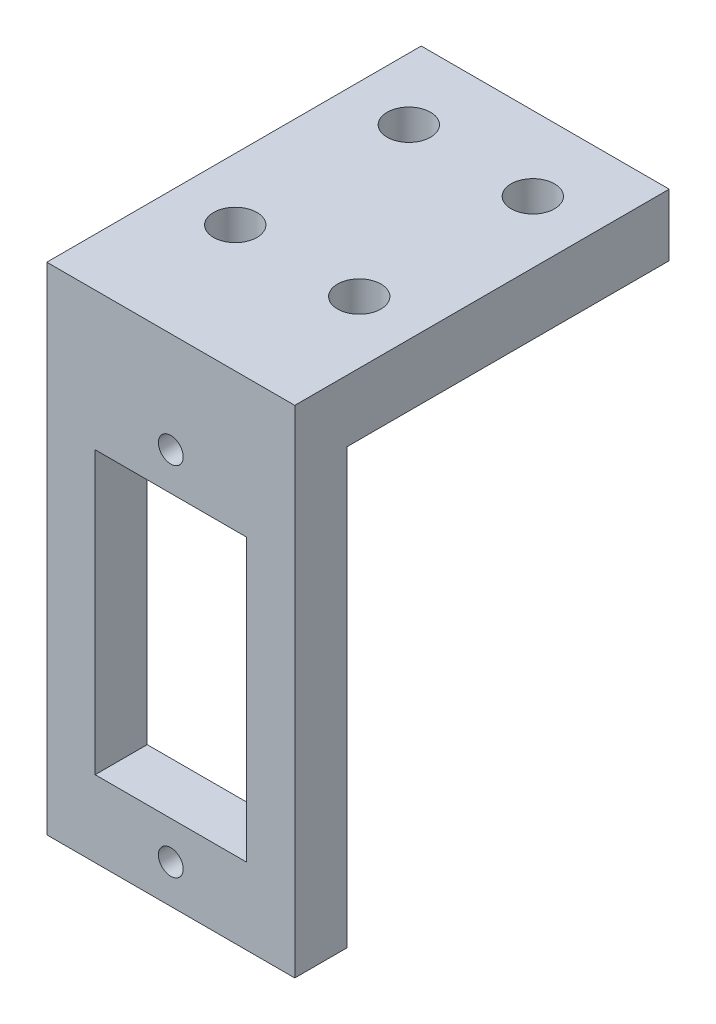
from build123d import *

# Parameters (mm, degrees)
SKETCH1_W           = 20
SKETCH1_H           = 45
BOSS_EXTRUDE1_DEPTH = 4.2
SKETCH2_W           = 12.2
SKETCH2_H           = 22.7
CUT_EXTRUDE1_DEPTH  = 5
SKETCH3_R           = 1
SKETCH3_R_2         = 1.001337469
CUT_EXTRUDE2_DEPTH  = 5
SKETCH4_W           = 20
SKETCH4_H           = 5
BOSS_EXTRUDE2_DEPTH = 26
SKETCH5_R           = 1.75
CUT_EXTRUDE3_DEPTH  = 15
SKETCH6_W           = 20
SKETCH6_H           = 5
CUT_EXTRUDE4_DEPTH  = 15


with BuildPart() as part:
    # Sketch1 → Boss-Extrude1 (new body)
    with BuildSketch(Plane.XY):
        Rectangle(SKETCH1_W, SKETCH1_H)
    extrude(amount=BOSS_EXTRUDE1_DEPTH)

    # Sketch2 → Cut-Extrude1 (cut)
    with BuildSketch(Plane(origin=(0, 0, 0), x_dir=(-1, 0, 0), z_dir=(0, 0, -1))):
        Rectangle(SKETCH2_W, SKETCH2_H)
    extrude(amount=-CUT_EXTRUDE1_DEPTH, mode=Mode.SUBTRACT)

    # Sketch3 → Cut-Extrude2 (cut)
    with BuildSketch(Plane.XY.offset(4.2)):
        with Locations((0, 14.4)):
            Circle(SKETCH3_R)
        with Locations((0, -14.396360879)):
            Circle(SKETCH3_R_2)
    extrude(amount=-CUT_EXTRUDE2_DEPTH, mode=Mode.SUBTRACT)

    # Sketch4 → Boss-Extrude2 (add)
    with BuildSketch(Plane(origin=(0, 0, 0), x_dir=(-1, 0, 0), z_dir=(0, 0, -1))):
        with Locations((0, 20)):
            Rectangle(SKETCH4_W, SKETCH4_H)
    extrude(amount=BOSS_EXTRUDE2_DEPTH)

    # Sketch5 → Cut-Extrude3 (cut)
    with BuildSketch(Plane(origin=(0, 22.5, 0), x_dir=(1, 0, 0), z_dir=(0, 1, 0))):
        with Locations((-5, 6)):
            Circle(SKETCH5_R)
        with Locations((5, 6)):
            Circle(SKETCH5_R)
        with Locations((5, 20)):
            Circle(SKETCH5_R)
        with Locations((-5, 20)):
            Circle(SKETCH5_R)
    extrude(amount=-CUT_EXTRUDE3_DEPTH, mode=Mode.SUBTRACT)

    # Sketch6 → Cut-Extrude4 (cut)
    with BuildSketch(Plane.XY.offset(4.2)):
        with Locations((0, -20)):
            Rectangle(SKETCH6_W, SKETCH6_H)
    extrude(amount=-CUT_EXTRUDE4_DEPTH, mode=Mode.SUBTRACT)


solid = part.part
